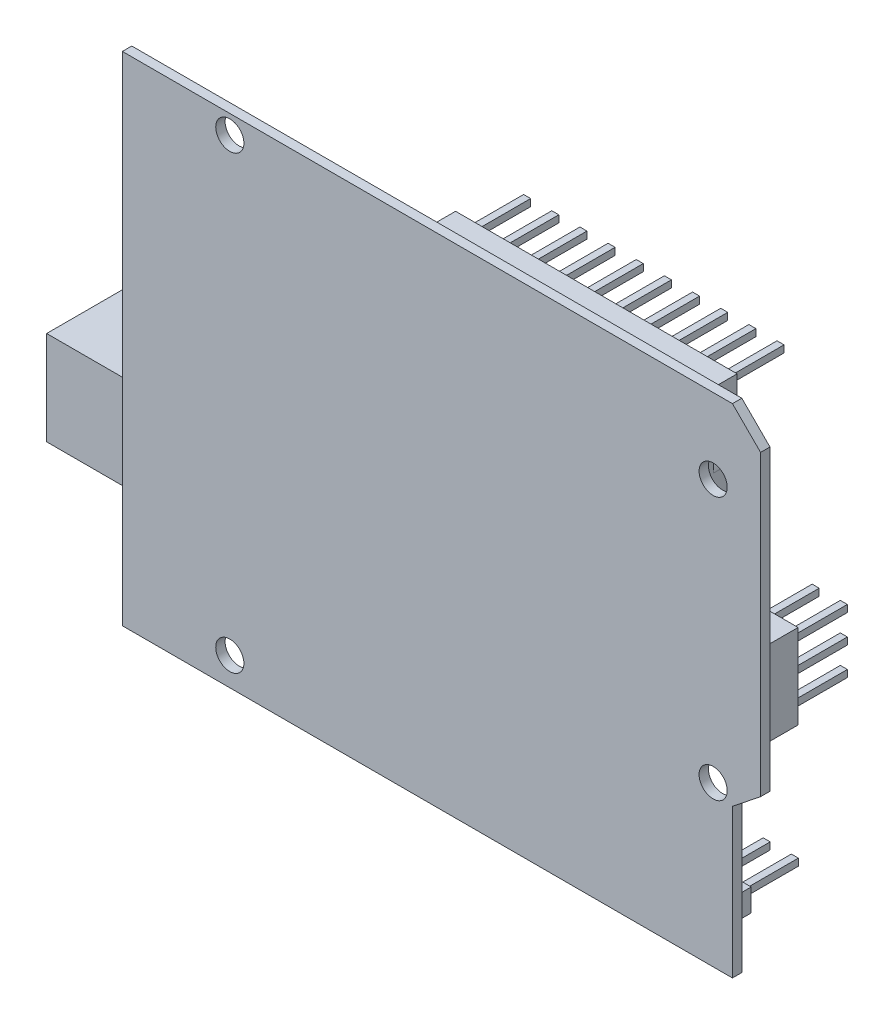
from build123d import *

# Parameters (mm, degrees)
BOSS_EXTRUDE1_DEPTH  = 1
SKETCH2_W            = 16
SKETCH2_H            = 10
BOSS_EXTRUDE2_DEPTH  = 10
SKETCH3_W            = 4.889113018
SKETCH3_H            = 5.37802432
CUT_EXTRUDE1_DEPTH   = 10
SKETCH4_W            = 45
SKETCH4_H            = 2.4
SKETCH4_W_2          = 30
BOSS_EXTRUDE3_DEPTH  = 4
SKETCH5_W            = 35
SKETCH5_H            = 10
BOSS_EXTRUDE4_DEPTH  = 7
SKETCH6_W            = 35
SKETCH6_H            = 1.5
CUT_EXTRUDE2_DEPTH   = 4
FILLET1_R            = 1
SKETCH7_R            = 1.5
CUT_EXTRUDE3_DEPTH   = 4
SKETCH8_W            = 0.75
SKETCH8_H            = 0.75
BOSS_EXTRUDE5_DEPTH  = 6
LPATTERN1_COUNT      = 10
LPATTERN1_PITCH      = 3
SKETCH9_W            = 0.75
SKETCH9_H            = 0.75
BOSS_EXTRUDE6_DEPTH  = 6
LPATTERN2_COUNT      = 15
LPATTERN2_PITCH      = 3
SKETCH10_R           = 2.5
BOSS_EXTRUDE7_DEPTH  = 6
SKETCH11_W           = 4.8
SKETCH11_H           = 9
BOSS_EXTRUDE8_DEPTH  = 4
SKETCH12_W           = 0.75
SKETCH12_H           = 0.75
BOSS_EXTRUDE9_DEPTH  = 6
LPATTERN3_COUNT      = 3
LPATTERN3_PITCH      = 3
LPATTERN3_COUNT_DIR2 = 2
LPATTERN3_PITCH_DIR2 = 3
SKETCH13_W           = 14.120912951
SKETCH13_H           = 4.362558473
BOSS_EXTRUDE10_DEPTH = 4
FILLET2_R            = 1


with BuildPart() as part:
    # Sketch1 → Boss-Extrude1 (new body)
    with BuildSketch(Plane.XY):
        Polygon((22.754016647, 124.270947632), (19.754016647, 127.270947632), (-45.245983353, 127.270947632), (-45.245983353, 74.270947632), (19.754016647, 74.270947632), (19.754016647, 90.113910289), (22.754016647, 92.500164177), align=None)
    extrude(amount=-BOSS_EXTRUDE1_DEPTH)

    # Sketch2 → Boss-Extrude2 (add)
    with BuildSketch(Plane(origin=(0, 0, -1), x_dir=(-1, 0, 0), z_dir=(0, 0, -1))):
        with Locations((46.316496684, 91.208096568)):
            Rectangle(SKETCH2_W, SKETCH2_H)
    extrude(amount=BOSS_EXTRUDE2_DEPTH)

    # Sketch3 → Cut-Extrude1 (cut)
    with BuildSketch(Plane.ZY.offset(54.316496684)):
        with Locations((-6.06540843, 91.2419286)):
            Rectangle(SKETCH3_W, SKETCH3_H)
    extrude(amount=-CUT_EXTRUDE1_DEPTH, mode=Mode.SUBTRACT)

    # Sketch4 → Boss-Extrude3 (add)
    with BuildSketch(Plane(origin=(0, 0, -1), x_dir=(-1, 0, 0), z_dir=(0, 0, -1))):
        with Locations((5.745983353, 77.470947632)):
            Rectangle(SKETCH4_W, SKETCH4_H)
        with Locations((-0.254016647, 124.070947632)):
            Rectangle(SKETCH4_W_2, SKETCH4_H)
    extrude(amount=BOSS_EXTRUDE3_DEPTH)

    # Sketch5 → Boss-Extrude4 (add)
    with BuildSketch(Plane(origin=(0, 0, -1), x_dir=(-1, 0, 0), z_dir=(0, 0, -1))):
        with Locations((3.745983353, 113.370947632)):
            Rectangle(SKETCH5_W, SKETCH5_H)
    extrude(amount=BOSS_EXTRUDE4_DEPTH)

    # Sketch6 → Cut-Extrude2 (cut)
    with BuildSketch(Plane(origin=(0, 0, -8), x_dir=(-1, 0, 0), z_dir=(0, 0, -1))):
        with Locations((3.745983353, 117.620947632)):
            Rectangle(SKETCH6_W, SKETCH6_H)
        with Locations((3.745983353, 109.120947632)):
            Rectangle(SKETCH6_W, SKETCH6_H)
    extrude(amount=-CUT_EXTRUDE2_DEPTH, mode=Mode.SUBTRACT)

    # Fillet1
    fillet1_edges = [part.edges().sort_by_distance(p)[0] for p in [
        (13.754016647, 109.870947632, -6),
        (-21.245983353, 109.870947632, -6),
        (13.754016647, 116.870947632, -6),
        (-21.245983353, 116.870947632, -6),
    ]]
    fillet(fillet1_edges, radius=FILLET1_R)

    # Sketch7 → Cut-Extrude3 (cut)
    with BuildSketch(Plane(origin=(0, 0, -1), x_dir=(-1, 0, 0), z_dir=(0, 0, -1))):
        with Locations((-17.700101194, 119.270947632)):
            Circle(SKETCH7_R)
        with Locations((-17.700101194, 91.270947632)):
            Circle(SKETCH7_R)
        with Locations((33.799898806, 125.270947632)):
            Circle(SKETCH7_R)
        with Locations((33.799898806, 77.270947632)):
            Circle(SKETCH7_R)
    extrude(amount=-CUT_EXTRUDE3_DEPTH, mode=Mode.SUBTRACT)

    # Sketch8 → Boss-Extrude5 (add)
    with BuildSketch(Plane(origin=(0, 0, -5), x_dir=(-1, 0, 0), z_dir=(0, 0, -1))):
        with Locations((-13.879016647, 124.070947632)):
            Rectangle(SKETCH8_W, SKETCH8_H)
    boss_extrude5 = extrude(amount=BOSS_EXTRUDE5_DEPTH)

    # LPattern1: Boss-Extrude5 ×10
    with Locations(*[(-i * LPATTERN1_PITCH, 0, 0) for i in range(1, LPATTERN1_COUNT)]):
        add(boss_extrude5)

    # Sketch9 → Boss-Extrude6 (add)
    with BuildSketch(Plane(origin=(0, 0, -5), x_dir=(-1, 0, 0), z_dir=(0, 0, -1))):
        with Locations((-15.402792453, 77.470947632)):
            Rectangle(SKETCH9_W, SKETCH9_H)
    boss_extrude6 = extrude(amount=BOSS_EXTRUDE6_DEPTH)

    # LPattern2: Boss-Extrude6 ×15
    with Locations(*[(-i * LPATTERN2_PITCH, 0, 0) for i in range(1, LPATTERN2_COUNT)]):
        add(boss_extrude6)

    # Sketch10 → Boss-Extrude7 (add)
    with BuildSketch(Plane(origin=(0, 0, -1), x_dir=(-1, 0, 0), z_dir=(0, 0, -1))):
        with Locations((26.546732083, 118.214976991)):
            Circle(SKETCH10_R)
        with Locations((31.940661119, 118.214976991)):
            Circle(SKETCH10_R)
    extrude(amount=BOSS_EXTRUDE7_DEPTH)

    # Sketch11 → Boss-Extrude8 (add)
    with BuildSketch(Plane(origin=(0, 0, -1), x_dir=(-1, 0, 0), z_dir=(0, 0, -1))):
        with Locations((-19.349242758, 100.613910289)):
            Rectangle(SKETCH11_W, SKETCH11_H)
    extrude(amount=BOSS_EXTRUDE8_DEPTH)

    # Sketch12 → Boss-Extrude9 (add)
    with BuildSketch(Plane(origin=(0, 0, -5), x_dir=(-1, 0, 0), z_dir=(0, 0, -1))):
        with Locations((-20.624242758, 97.488910289)):
            Rectangle(SKETCH12_W, SKETCH12_H)
    boss_extrude9 = extrude(amount=BOSS_EXTRUDE9_DEPTH)

    # LPattern3: Boss-Extrude9 3 × 2
    with Locations(*[(-j * LPATTERN3_PITCH_DIR2, i * LPATTERN3_PITCH, 0) for i in range(LPATTERN3_COUNT) for j in range(LPATTERN3_COUNT_DIR2) if (i, j) != (0, 0)]):
        add(boss_extrude9)

    # Sketch13 → Boss-Extrude10 (add)
    with BuildSketch(Plane(origin=(0, 0, -1), x_dir=(-1, 0, 0), z_dir=(0, 0, -1))):
        with Locations((23.447660741, 101.747194556)):
            Rectangle(SKETCH13_W, SKETCH13_H)
    extrude(amount=BOSS_EXTRUDE10_DEPTH)

    # Fillet2
    fillet2_edges = [part.edges().sort_by_distance(p)[0] for p in [
        (-16.387204265, 103.928473792, -3),
        (-16.387204265, 99.565915319, -3),
        (-30.508117216, 99.565915319, -3),
        (-30.508117216, 103.928473792, -3),
    ]]
    fillet(fillet2_edges, radius=FILLET2_R)


solid = part.part
